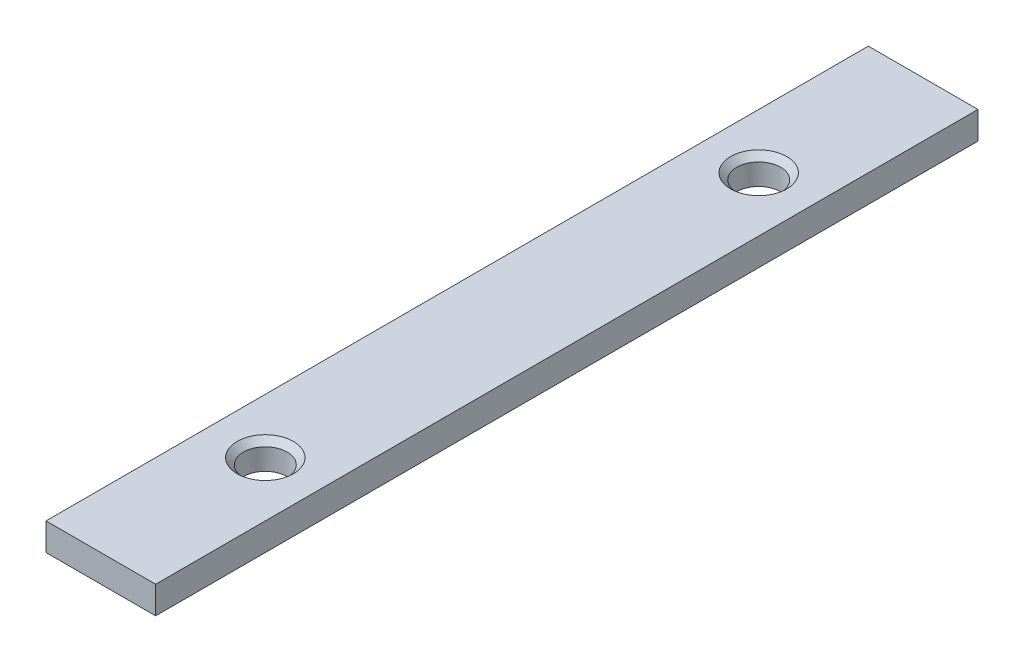
from build123d import *

# Parameters (mm, degrees)
SKETCH1_W                       = 4
SKETCH1_H                       = 30
BOSS_EXTRUDE1_DEPTH             = 1
M2X0_4_TAPPED_HOLE1_D           = 1.6
M2X0_4_TAPPED_HOLE1_DEPTH       = 11.2
M2X0_4_TAPPED_HOLE1_CSINK_D     = 2.05
M2X0_4_TAPPED_HOLE1_CSINK_ANGLE = 90
M2X0_4_TAPPED_HOLE1_TIP         = 0.480688495


with BuildPart() as part:
    # Sketch1 → Boss-Extrude1 (new body)
    with BuildSketch(Plane(origin=(0, 0, 0), x_dir=(1, 0, 0), z_dir=(0, 1, 0))):
        with Locations((2, 15)):
            Rectangle(SKETCH1_W, SKETCH1_H)
    extrude(amount=BOSS_EXTRUDE1_DEPTH)

    # M2x0.4 Tapped Hole1
    with Locations(Plane(origin=(2, 1, -24), x_dir=(0, 0, 1), z_dir=(0, 1, 0))):
        with Locations((0, 0), (18, 0)):
            CounterSinkHole(M2X0_4_TAPPED_HOLE1_D / 2, M2X0_4_TAPPED_HOLE1_CSINK_D / 2, depth=M2X0_4_TAPPED_HOLE1_DEPTH, counter_sink_angle=M2X0_4_TAPPED_HOLE1_CSINK_ANGLE)
            with Locations((0, 0, -(M2X0_4_TAPPED_HOLE1_DEPTH + M2X0_4_TAPPED_HOLE1_TIP / 2))):  # 118° drill point
                Cone(0, M2X0_4_TAPPED_HOLE1_D / 2, M2X0_4_TAPPED_HOLE1_TIP, mode=Mode.SUBTRACT)


solid = part.part
